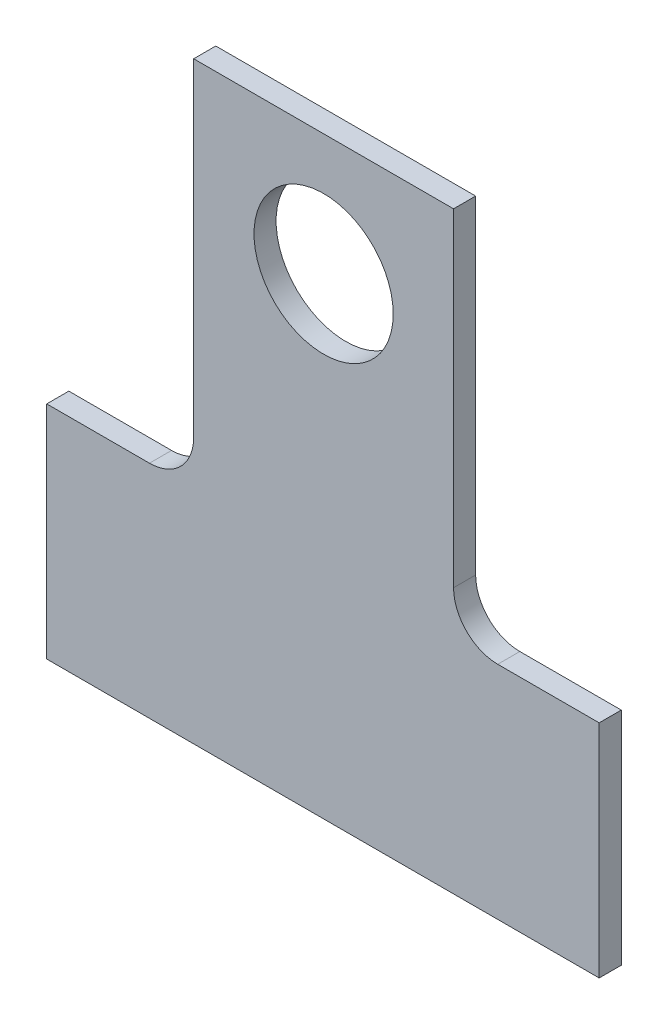
from build123d import *

# Parameters (mm, degrees)
DODANIE_WYCI_GNI_CIE1_DEPTH = 1
SZKIC2_R                    = 3.15
WYTNIJ_WYCI_GNI_CIE1_DEPTH  = 1


with BuildPart() as part:
    # Szkic1 → Dodanie-wyciągnięcie1 (new body)
    with BuildSketch(Plane.XY):
        with BuildLine():
            Line((-12.5, -6), (-12.5, -16))
            Line((-12.5, -16), (12.5, -16))
            Line((12.5, -16), (12.5, -6))
            Line((12.5, -6), (7.91, -6))
            ThreePointArc((7.91, -6), (6.495786438, -5.414213562), (5.91, -4))
            Line((5.91, -4), (5.91, 5.45))
            Line((5.91, 5.45), (5.91, 6.85))
            Line((5.91, 6.85), (5.91, 10.85))
            Line((5.91, 10.85), (-5.85, 10.85))
            Line((-5.85, 10.85), (-5.85, 6.85))
            Line((-5.85, 6.85), (-5.85, 5.45))
            Line((-5.85, 5.45), (-5.85, -4))
            ThreePointArc((-5.85, -4), (-6.435786438, -5.414213562), (-7.85, -6))
            Line((-7.85, -6), (-12.5, -6))
        make_face()
    extrude(amount=DODANIE_WYCI_GNI_CIE1_DEPTH)

    # Szkic2 → Wytnij-wyciągnięcie1 (cut)
    with BuildSketch(Plane.XY.offset(1)):
        with Locations((0.03, 5.36)):
            Circle(SZKIC2_R)
    extrude(amount=-WYTNIJ_WYCI_GNI_CIE1_DEPTH, mode=Mode.SUBTRACT)


solid = part.part
